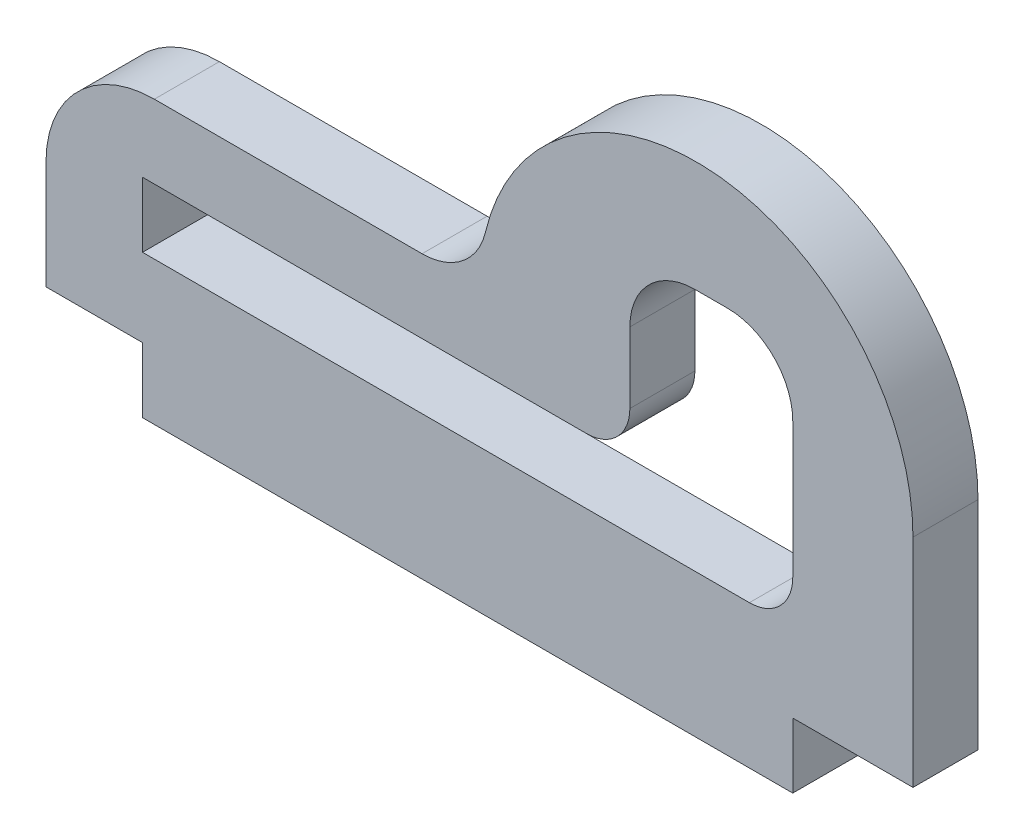
from build123d import *

# Parameters (mm, degrees)
SALIENTE_EXTRUIR1_DEPTH = 3


with BuildPart() as part:
    # Croquis1 → Saliente-Extruir1 (new body)
    with BuildSketch(Plane.XY):
        with BuildLine():
            Line((-2.649110641, 0), (-15, 0))
            ThreePointArc((-15, 0), (-18.535533906, -1.464466094), (-20, -5))
            Line((-20, -5), (-20, -10))
            Line((-20, -10), (-15.546822742, -10))
            Line((-15.546822742, -10), (-15.546822742, -13))
            Line((-15.546822742, -13), (14.453177258, -13))
            Line((14.453177258, -13), (14.453177258, -10))
            Line((14.453177258, -10), (20, -10))
            Line((20, -10), (20, 0))
            ThreePointArc((20, 0), (11.161711866, 9.932292059), (0.269914892, 2.307692308))
            ThreePointArc((0.269914892, 2.307692308), (-0.788589622, 0.646606378), (-2.649110641, 0))
        make_face()
        with BuildLine():
            Line((-15.546822742, -6.391304348), (12.453177258, -6.391304348))
            ThreePointArc((12.453177258, -6.391304348), (13.86739082, -5.80551791), (14.453177258, -4.391304348))
            Line((14.453177258, -4.391304348), (14.453177258, -3.391304348))
            Line((14.453177258, -3.391304348), (14.453177258, 1.869565217))
            ThreePointArc((14.453177258, 1.869565217), (13.574497601, 3.990885561), (11.453177258, 4.869565217))
            Line((11.453177258, 4.869565217), (9.93812709, 4.869565217))
            ThreePointArc((9.93812709, 4.869565217), (7.816806747, 3.990885561), (6.93812709, 1.869565217))
            Line((6.93812709, 1.869565217), (6.93812709, -1.391304348))
            ThreePointArc((6.93812709, -1.391304348), (6.352340653, -2.80551791), (4.93812709, -3.391304348))
            Line((4.93812709, -3.391304348), (-15.546822742, -3.391304348))
            Line((-15.546822742, -3.391304348), (-15.546822742, -6.391304348))
        make_face(mode=Mode.SUBTRACT)
    extrude(amount=SALIENTE_EXTRUIR1_DEPTH)


solid = part.part
